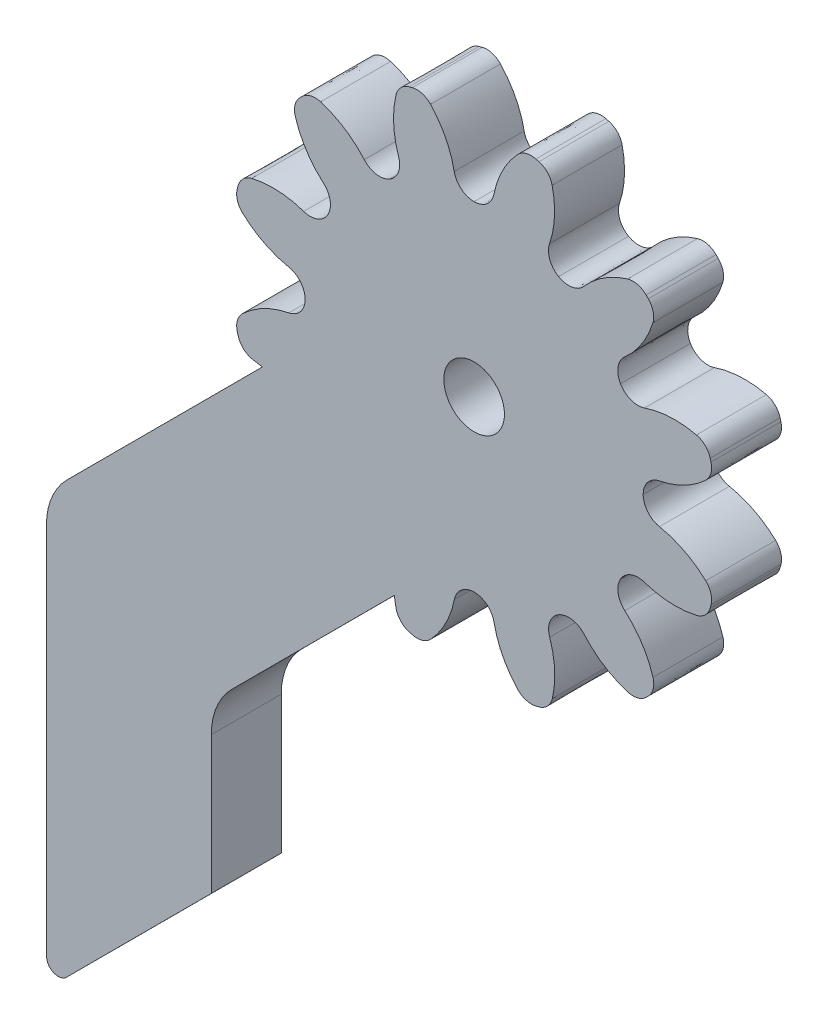
from build123d import *

# Parameters (mm, degrees)
MODEL_R             = 1.299950005
BOSS_EXTRUDE1_DEPTH = 3


with BuildPart() as part:
    # Model → Boss-Extrude1 (new body)
    with BuildSketch(Plane.XY):
        with BuildLine():
            Line((37.189605486, 26.041238758), (37.195110175, 19.535471105))
            ThreePointArc((37.195110175, 19.535471105), (37.503232625, 19.0739835), (38.047685111, 19.181136399))
            Line((38.047685111, 19.181136399), (38.048794798, 19.182246883))
            Line((38.048794798, 19.182246883), (44.264041459, 25.401952228))
            Line((44.264041459, 25.401952228), (44.262098388, 31.301118881))
            ThreePointArc((44.262098388, 31.301118881), (44.489991399, 32.44926525), (45.139978112, 33.422760284))
            Line((45.139978112, 33.422760284), (52.108955967, 40.396679623))
            add(Edge.make_bspline(
                [(52.187442208, 39.947015882), (52.152852698, 40.095294592), (52.126694033, 40.245422852), (52.108955967, 40.396679623)],
                knots=[0, 0, 0, 0, 1, 1, 1, 1], degree=3))
            add(Edge.make_bspline(
                [(52.754760171, 39.357428884), (52.471855853, 39.435038462), (52.25416892, 39.661366542), (52.187442208, 39.947015882)],
                knots=[0, 0, 0, 0, 1, 1, 1, 1], degree=3))
            add(Edge.make_bspline(
                [(52.885213668, 39.322483426), (52.841687988, 39.333836627), (52.798249841, 39.3454937), (52.754760171, 39.357428884)],
                knots=[0, 0, 0, 0, 1, 1, 1, 1], degree=3))
            add(Edge.make_bspline(
                [(53.671209711, 39.550078462), (53.470782053, 39.335823465), (53.169111731, 39.2484379), (52.885213668, 39.322483426)],
                knots=[0, 0, 0, 0, 1, 1, 1, 1], degree=3))
            add(Edge.make_bspline(
                [(54.686704051, 41.533682126), (54.540556953, 40.790416712), (54.188724969, 40.103109571), (53.671209711, 39.550078462)],
                knots=[0, 0, 0, 0, 1, 1, 1, 1], degree=3))
            add(Edge.make_bspline(
                [(54.686704051, 41.533682126), (54.76650909, 41.939822072), (55.122582316, 42.232748201), (55.536488264, 42.23291184)],
                knots=[0, 0, 0, 0, 0.333333333, 0.333333333, 0.333333333, 0.333333333], degree=3))
            add(Edge.make_bspline(
                [(55.536488264, 42.23291184), (55.950476619, 42.233018831), (56.30674127, 41.940313828), (56.386872469, 41.53417507)],
                knots=[0.333333333, 0.333333333, 0.333333333, 0.333333333, 1, 1, 1, 1], degree=3))
            add(Edge.make_bspline(
                [(57.403738428, 39.551335424), (56.885824427, 40.104050095), (56.533528055, 40.791074895), (56.386872469, 41.53417507)],
                knots=[0, 0, 0, 0, 1, 1, 1, 1], degree=3))
            add(Edge.make_bspline(
                [(58.189875277, 39.324388943), (57.906059973, 39.250091477), (57.604346213, 39.33723284), (57.403738428, 39.551335424)],
                knots=[0, 0, 0, 0, 1, 1, 1, 1], degree=3))
            add(Edge.make_bspline(
                [(58.320323753, 39.359342842), (58.276938802, 39.347422019), (58.233445681, 39.335696898), (58.189875277, 39.324388943)],
                knots=[0, 0, 0, 0, 1, 1, 1, 1], degree=3))
            add(Edge.make_bspline(
                [(58.887211912, 39.949423332), (58.820711657, 39.663615064), (58.603191153, 39.437204221), (58.320323753, 39.359342842)],
                knots=[0, 0, 0, 0, 1, 1, 1, 1], degree=3))
            add(Edge.make_bspline(
                [(58.774858739, 42.174982546), (59.019887583, 41.458305132), (59.058827451, 40.687195246), (58.887211912, 39.949423332)],
                knots=[0, 0, 0, 0, 1, 1, 1, 1], degree=3))
            add(Edge.make_bspline(
                [(58.774858739, 42.174982546), (58.640877437, 42.566686402), (58.802817018, 42.998398149), (59.161193424, 43.205526229)],
                knots=[0, 0, 0, 0, 0.333333333, 0.333333333, 0.333333333, 0.333333333], degree=3))
            add(Edge.make_bspline(
                [(59.161193424, 43.205526229), (59.519652239, 43.412597661), (59.974451544, 43.337204742), (60.246984591, 43.025607714)],
                knots=[0.333333333, 0.333333333, 0.333333333, 0.333333333, 1, 1, 1, 1], degree=3))
            add(Edge.make_bspline(
                [(62.119052616, 41.816785127), (61.394225004, 42.036535945), (60.745565768, 42.455360162), (60.246984591, 43.025607714)],
                knots=[0, 0, 0, 0, 1, 1, 1, 1], degree=3))
            add(Edge.make_bspline(
                [(62.913399468, 42.01327833), (62.704653561, 41.807046843), (62.399825266, 41.731661163), (62.119052616, 41.816785127)],
                knots=[0, 0, 0, 0, 1, 1, 1, 1], degree=3))
            add(Edge.make_bspline(
                [(63.008816659, 42.108837995), (62.977155155, 42.076723837), (62.94535972, 42.044944437), (62.913399468, 42.01327833)],
                knots=[0, 0, 0, 0, 1, 1, 1, 1], degree=3))
            add(Edge.make_bspline(
                [(63.204675564, 42.903238782), (63.289973766, 42.622540177), (63.214853343, 42.317659869), (63.008816659, 42.108837995)],
                knots=[0, 0, 0, 0, 1, 1, 1, 1], degree=3))
            add(Edge.make_bspline(
                [(61.994610691, 44.774489273), (62.565197653, 44.276335111), (62.984475555, 43.627967839), (63.204675564, 42.903238782)],
                knots=[0, 0, 0, 0, 1, 1, 1, 1], degree=3))
            add(Edge.make_bspline(
                [(61.994610691, 44.774489273), (61.68276852, 45.046730325), (61.607073353, 45.501513627), (61.814046923, 45.860161841)],
                knots=[0, 0, 0, 0, 0.333333333, 0.333333333, 0.333333333, 0.333333333], degree=3))
            add(Edge.make_bspline(
                [(61.814046923, 45.860161841), (62.02082479, 46.218701886), (62.452399951, 46.380852835), (62.844210587, 46.247190477)],
                knots=[0.333333333, 0.333333333, 0.333333333, 0.333333333, 1, 1, 1, 1], degree=3))
            add(Edge.make_bspline(
                [(65.069842487, 46.136336448), (64.332234315, 45.964305915), (63.561057078, 46.002589071), (62.844210587, 46.247190477)],
                knots=[0, 0, 0, 0, 1, 1, 1, 1], degree=3))
            add(Edge.make_bspline(
                [(65.659486132, 46.703736819), (65.581819907, 46.420750093), (65.355574236, 46.203006514), (65.069842487, 46.136336448)],
                knots=[0, 0, 0, 0, 1, 1, 1, 1], degree=3))
            add(Edge.make_bspline(
                [(65.694374943, 46.834107909), (65.683021742, 46.790582229), (65.671447077, 46.747087434), (65.659486132, 46.703736819)],
                knots=[0, 0, 0, 0, 1, 1, 1, 1], degree=3))
            add(Edge.make_bspline(
                [(65.466918963, 47.620129713), (65.681117313, 47.419619647), (65.768420469, 47.118005972), (65.694374943, 46.834107909)],
                knots=[0, 0, 0, 0, 1, 1, 1, 1], degree=3))
            add(Edge.make_bspline(
                [(63.483315299, 48.635624053), (64.226441657, 48.489451193), (64.913748798, 48.137619209), (65.466918963, 47.620129713)],
                knots=[0, 0, 0, 0, 1, 1, 1, 1], degree=3))
            add(Edge.make_bspline(
                [(63.483315299, 48.635624053), (63.077092944, 48.715485738), (62.784110168, 49.071476556), (62.784059823, 49.48554732)],
                knots=[0, 0, 0, 0, 0.333333333, 0.333333333, 0.333333333, 0.333333333], degree=3))
            add(Edge.make_bspline(
                [(62.784059823, 49.48554732), (62.783896185, 49.899453268), (63.076544541, 50.25563551), (63.4826833, 50.335766709)],
                knots=[0.333333333, 0.333333333, 0.333333333, 0.333333333, 1, 1, 1, 1], degree=3))
            add(Edge.make_bspline(
                [(65.465522945, 51.352632668), (64.912808274, 50.834718667), (64.225783474, 50.482422296), (63.4826833, 50.335766709)],
                knots=[0, 0, 0, 0, 1, 1, 1, 1], degree=3))
            add(Edge.make_bspline(
                [(65.692608481, 52.138795278), (65.766766892, 51.854954213), (65.679625529, 51.553240453), (65.465522945, 51.352632668)],
                knots=[0, 0, 0, 0, 1, 1, 1, 1], degree=3))
            add(Edge.make_bspline(
                [(65.657515528, 52.269217993), (65.669518759, 52.225776395), (65.681161471, 52.182339922), (65.692608481, 52.138795278)],
                knots=[0, 0, 0, 0, 1, 1, 1, 1], degree=3))
            add(Edge.make_bspline(
                [(65.067517445, 52.836049505), (65.353243305, 52.769605897), (65.579654148, 52.552085393), (65.657515528, 52.269217993)],
                knots=[0, 0, 0, 0, 1, 1, 1, 1], degree=3))
            add(Edge.make_bspline(
                [(62.841875823, 52.723752979), (63.558609884, 52.968864231), (64.329802178, 53.007747453), (65.067517445, 52.836049505)],
                knots=[0, 0, 0, 0, 1, 1, 1, 1], degree=3))
            add(Edge.make_bspline(
                [(62.841875823, 52.723752979), (62.450228614, 52.589854086), (62.018542629, 52.751654611), (61.811471196, 53.110113426)],
                knots=[0, 0, 0, 0, 0.333333333, 0.333333333, 0.333333333, 0.333333333], degree=3))
            add(Edge.make_bspline(
                [(61.811471196, 53.110113426), (61.604260708, 53.468546479), (61.679653627, 53.923345784), (61.991333063, 54.195822184)],
                knots=[0.333333333, 0.333333333, 0.333333333, 0.333333333, 1, 1, 1, 1], degree=3))
            add(Edge.make_bspline(
                [(63.200073243, 56.067946857), (62.980404833, 55.343062597), (62.561580615, 54.694403361), (61.991333063, 54.195822184)],
                knots=[0, 0, 0, 0, 1, 1, 1, 1], degree=3))
            add(Edge.make_bspline(
                [(63.003662448, 56.862237061), (63.209811526, 56.653547801), (63.285197206, 56.348719506), (63.200073243, 56.067946857)],
                knots=[0, 0, 0, 0, 1, 1, 1, 1], degree=3))
            add(Edge.make_bspline(
                [(62.908102782, 56.957654252), (62.940134532, 56.926049395), (62.97197058, 56.894336368), (63.003662448, 56.862237061)],
                knots=[0, 0, 0, 0, 1, 1, 1, 1], degree=3))
            add(Edge.make_bspline(
                [(62.113676235, 57.153652213), (62.394374839, 57.238950415), (62.6991985, 57.163747583), (62.908102782, 56.957654252)],
                knots=[0, 0, 0, 0, 1, 1, 1, 1], degree=3))
            add(Edge.make_bspline(
                [(60.242369096, 55.943504931), (60.740523258, 56.514091893), (61.388890531, 56.933369796), (62.113676235, 57.153652213)],
                knots=[0, 0, 0, 0, 1, 1, 1, 1], degree=3))
            add(Edge.make_bspline(
                [(60.242369096, 55.943504931), (59.970128044, 55.63166276), (59.515344742, 55.555967593), (59.156778936, 55.762884516)],
                knots=[0, 0, 0, 0, 0.333333333, 0.333333333, 0.333333333, 0.333333333], degree=3))
            add(Edge.make_bspline(
                [(59.156778936, 55.762884516), (58.798238892, 55.969662383), (58.636005535, 56.401294191), (58.769667892, 56.793104827)],
                knots=[0.333333333, 0.333333333, 0.333333333, 0.333333333, 1, 1, 1, 1], degree=3))
            add(Edge.make_bspline(
                [(58.880521921, 59.018736727), (59.052691509, 58.281154316), (59.014269298, 57.509951318), (58.769667892, 56.793104827)],
                knots=[0, 0, 0, 0, 1, 1, 1, 1], degree=3))
            add(Edge.make_bspline(
                [(58.313178197, 59.608462781), (58.596108276, 59.530714147), (58.813851855, 59.304468476), (58.880521921, 59.018736727)],
                knots=[0, 0, 0, 0, 1, 1, 1, 1], degree=3))
            add(Edge.make_bspline(
                [(58.182750461, 59.643269183), (58.226332788, 59.63199839), (58.269770935, 59.620341317), (58.313178197, 59.608462781)],
                knots=[0, 0, 0, 0, 1, 1, 1, 1], degree=3))
            add(Edge.make_bspline(
                [(57.396811065, 59.415756556), (57.597238723, 59.630011553), (57.898852398, 59.717314709), (58.182750461, 59.643269183)],
                knots=[0, 0, 0, 0, 1, 1, 1, 1], degree=3))
            add(Edge.make_bspline(
                [(56.381316725, 57.432152892), (56.527463823, 58.175418306), (56.87923916, 58.862643038), (57.396811065, 59.415756556)],
                knots=[0, 0, 0, 0, 1, 1, 1, 1], degree=3))
            add(Edge.make_bspline(
                [(56.381316725, 57.432152892), (56.301372631, 57.025987184), (55.945381813, 56.733004408), (55.531393457, 56.732897417)],
                knots=[0, 0, 0, 0, 0.333333333, 0.333333333, 0.333333333, 0.333333333], degree=3))
            add(Edge.make_bspline(
                [(55.531393457, 56.732897417), (55.11748751, 56.732733778), (54.761222859, 57.025438781), (54.68109166, 57.43157754)],
                knots=[0.333333333, 0.333333333, 0.333333333, 0.333333333, 1, 1, 1, 1], degree=3))
            add(Edge.make_bspline(
                [(53.664225701, 59.414417185), (54.182139702, 58.861702514), (54.534436074, 58.174677714), (54.68109166, 57.43157754)],
                knots=[0, 0, 0, 0, 1, 1, 1, 1], degree=3))
            add(Edge.make_bspline(
                [(52.878145499, 59.641446074), (53.161904156, 59.715661132), (53.463617916, 59.62851977), (53.664225701, 59.414417185)],
                knots=[0, 0, 0, 0, 1, 1, 1, 1], degree=3))
            add(Edge.make_bspline(
                [(52.747697023, 59.606492176), (52.791081974, 59.618412999), (52.834518448, 59.630055711), (52.878145499, 59.641446074)],
                knots=[0, 0, 0, 0, 1, 1, 1, 1], degree=3))
            add(Edge.make_bspline(
                [(52.180808864, 59.016411685), (52.247252472, 59.302137545), (52.464829623, 59.528630797), (52.747697023, 59.606492176)],
                knots=[0, 0, 0, 0, 1, 1, 1, 1], degree=3))
            add(Edge.make_bspline(
                [(52.293162037, 56.790852471), (52.048133193, 57.507529885), (52.009193325, 58.278639772), (52.180808864, 59.016411685)],
                knots=[0, 0, 0, 0, 1, 1, 1, 1], degree=3))
            add(Edge.make_bspline(
                [(52.293162037, 56.790852471), (52.427004283, 56.399122854), (52.265203758, 55.967436869), (51.906827352, 55.760308789)],
                knots=[0, 0, 0, 0, 0.333333333, 0.333333333, 0.333333333, 0.333333333], degree=3))
            add(Edge.make_bspline(
                [(51.906827352, 55.760308789), (51.548368537, 55.553237356), (51.093512585, 55.628547867), (50.821092832, 55.940309712)],
                knots=[0.333333333, 0.333333333, 0.333333333, 0.333333333, 1, 1, 1, 1], degree=3))
            add(Edge.make_bspline(
                [(48.94896816, 57.149049891), (49.673795772, 56.929299073), (50.322455008, 56.510474855), (50.821092832, 55.940309712)],
                knots=[0, 0, 0, 0, 1, 1, 1, 1], degree=3))
            add(Edge.make_bspline(
                [(48.154621308, 56.952556688), (48.363310568, 57.158705766), (48.668138863, 57.234091447), (48.94896816, 57.149049891)],
                knots=[0, 0, 0, 0, 1, 1, 1, 1], degree=3))
            add(Edge.make_bspline(
                [(48.059204117, 56.856997022), (48.090808974, 56.889028772), (48.122661056, 56.920890581), (48.154621308, 56.952556688)],
                knots=[0, 0, 0, 0, 1, 1, 1, 1], degree=3))
            add(Edge.make_bspline(
                [(47.863345212, 56.062596236), (47.777964602, 56.343351488), (47.853167433, 56.648175149), (48.059204117, 56.856997022)],
                knots=[0, 0, 0, 0, 1, 1, 1, 1], degree=3))
            add(Edge.make_bspline(
                [(49.073410085, 54.191345745), (48.502823123, 54.689499906), (48.08354522, 55.337867179), (47.863345212, 56.062596236)],
                knots=[0, 0, 0, 0, 1, 1, 1, 1], degree=3))
            add(Edge.make_bspline(
                [(49.073410085, 54.191345745), (49.385252256, 53.919104692), (49.460890776, 53.464238982), (49.2540305, 53.105755585)],
                knots=[0, 0, 0, 0, 0.333333333, 0.333333333, 0.333333333, 0.333333333], degree=3))
            add(Edge.make_bspline(
                [(49.2540305, 53.105755585), (49.047195986, 52.747133132), (48.615620825, 52.584982183), (48.223810189, 52.718644541)],
                knots=[0.333333333, 0.333333333, 0.333333333, 0.333333333, 1, 1, 1, 1], degree=3))
            add(Edge.make_bspline(
                [(45.998121642, 52.829416161), (46.735786461, 53.001529103), (47.506907051, 52.963163538), (48.223810189, 52.718644541)],
                knots=[0, 0, 0, 0, 1, 1, 1, 1], degree=3))
            add(Edge.make_bspline(
                [(45.408534644, 52.262098198), (45.486144222, 52.545002516), (45.712389893, 52.762746096), (45.998121642, 52.829416161)],
                knots=[0, 0, 0, 0, 1, 1, 1, 1], degree=3))
            add(Edge.make_bspline(
                [(45.373589186, 52.131644701), (45.384942387, 52.175170381), (45.396573699, 52.218747583), (45.408534644, 52.262098198)],
                knots=[0, 0, 0, 0, 1, 1, 1, 1], degree=3))
            add(Edge.make_bspline(
                [(45.601101813, 51.345705305), (45.386846816, 51.546132963), (45.29954366, 51.847746638), (45.373589186, 52.131644701)],
                knots=[0, 0, 0, 0, 1, 1, 1, 1], degree=3))
            add(Edge.make_bspline(
                [(47.584705477, 50.330210965), (46.841522472, 50.476301417), (46.154215331, 50.8281334), (45.601101813, 51.345705305)],
                knots=[0, 0, 0, 0, 1, 1, 1, 1], degree=3))
            add(Edge.make_bspline(
                [(47.584705477, 50.330210965), (47.990927832, 50.250349279), (48.283853961, 49.894276053), (48.284017599, 49.480370106)],
                knots=[0, 0, 0, 0, 0.333333333, 0.333333333, 0.333333333, 0.333333333], degree=3))
            add(Edge.make_bspline(
                [(48.284017599, 49.480370106), (48.284124591, 49.06638175), (47.991476235, 48.710199508), (47.585337476, 48.630068309)],
                knots=[0.333333333, 0.333333333, 0.333333333, 0.333333333, 1, 1, 1, 1], degree=3))
            add(Edge.make_bspline(
                [(45.602441184, 47.613119941), (46.155155855, 48.131033942), (46.842180655, 48.483330314), (47.585337476, 48.630068309)],
                knots=[0, 0, 0, 0, 1, 1, 1, 1], degree=3))
            add(Edge.make_bspline(
                [(45.375412295, 46.827039739), (45.301253884, 47.110880804), (45.3883386, 47.412512156), (45.602441184, 47.613119941)],
                knots=[0, 0, 0, 0, 1, 1, 1, 1], degree=3))
            add(Edge.make_bspline(
                [(45.410448601, 46.696534616), (45.39844537, 46.739976214), (45.386859305, 46.783495096), (45.375412295, 46.827039739)],
                knots=[0, 0, 0, 0, 1, 1, 1, 1], degree=3))
            add(Edge.make_bspline(
                [(46.000446684, 46.129703104), (45.714720824, 46.196146712), (45.488309981, 46.413667217), (45.410448601, 46.696534616)],
                knots=[0, 0, 0, 0, 1, 1, 1, 1], degree=3))
            add(Edge.make_bspline(
                [(46.450157732, 46.051497777), (46.298903574, 46.069069907), (46.14879731, 46.095196704), (46.000446684, 46.129703104)],
                knots=[0, 0, 0, 0, 1, 1, 1, 1], degree=3))
            Line((46.450157732, 46.051497777), (38.067385209, 37.66288016))
            ThreePointArc((38.067385209, 37.66288016), (37.417432387, 36.689371103), (37.189505486, 35.541238758))
            Line((37.189505486, 35.541238758), (37.189605486, 26.041238758))
        make_face()
        with Locations((55.533969184, 49.482945832)):
            Circle(MODEL_R, mode=Mode.SUBTRACT)
    extrude(amount=BOSS_EXTRUDE1_DEPTH)


solid = part.part
